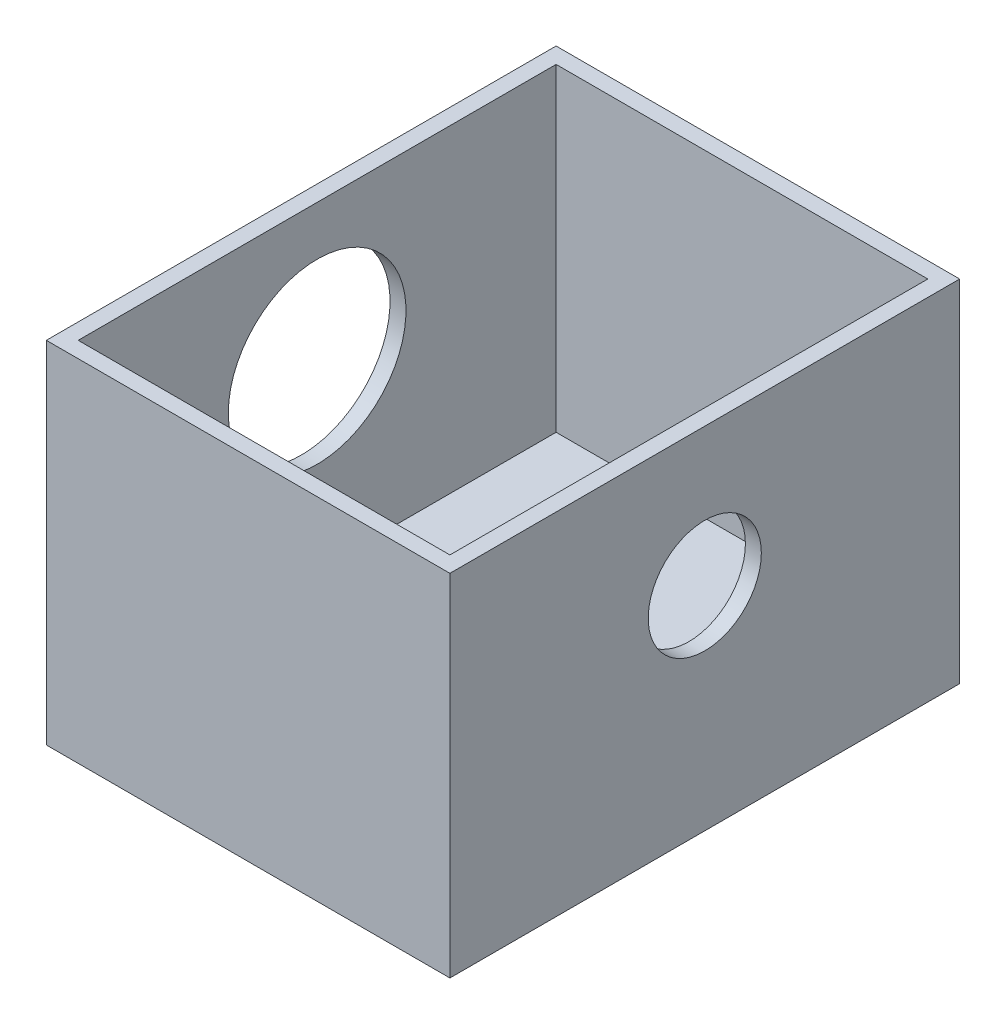
from build123d import *

# Parameters (mm, degrees)
SKETCH1_W                 = 9.652
SKETCH1_H                 = 12.192
BOSS_EXTRUDE1_DEPTH       = 8.382
SKETCH4_W                 = 8.89
SKETCH4_H                 = 11.43
CUT_EXTRUDE1_DEPTH        = 7.62
CUT_EXTRUDE2_REACH        = 11.652
SKETCH6_R                 = 2.12471
F_6_32_TAPPED_HOLE2_D     = 2.7051
F_6_32_TAPPED_HOLE2_DEPTH = 0.381


with BuildPart() as part:
    # Sketch1 → Boss-Extrude1 (new body)
    with BuildSketch(Plane(origin=(0, 0, 0), x_dir=(1, 0, 0), z_dir=(0, 1, 0))):
        with Locations((-3.14180083, 1.47973444)):
            Rectangle(SKETCH1_W, SKETCH1_H)
    extrude(amount=BOSS_EXTRUDE1_DEPTH)

    # Sketch4 → Cut-Extrude1 (cut)
    with BuildSketch(Plane(origin=(0, 8.382, 0), x_dir=(1, 0, 0), z_dir=(0, 1, 0))):
        with Locations((-3.14180083, 1.47973444)):
            Rectangle(SKETCH4_W, SKETCH4_H)
    extrude(amount=-CUT_EXTRUDE1_DEPTH, mode=Mode.SUBTRACT)

    # Sketch6 → Cut-Extrude2 (cut, up to next)
    with BuildSketch(Plane.ZY.offset(7.96780083), mode=Mode.PRIVATE) as cut_extrude2_sk1:
        with Locations((-1.47973444, 5.08)):
            Circle(SKETCH6_R)
    cut_extrude2_tool1 = extrude(cut_extrude2_sk1.sketch, amount=-CUT_EXTRUDE2_REACH, mode=Mode.PRIVATE) & part.part
    add(cut_extrude2_tool1.solids().sort_by_distance((-7.967801, 5.08, -1.479734))[0], mode=Mode.SUBTRACT)

    # 6-32 Tapped Hole2
    with Locations(Plane(origin=(1.68419917, 0, 0), x_dir=(0, 0, -1), z_dir=(1, 0, 0))):
        with Locations((1.47973444, 5.08)):
            Hole(F_6_32_TAPPED_HOLE2_D / 2, depth=F_6_32_TAPPED_HOLE2_DEPTH)


solid = part.part
